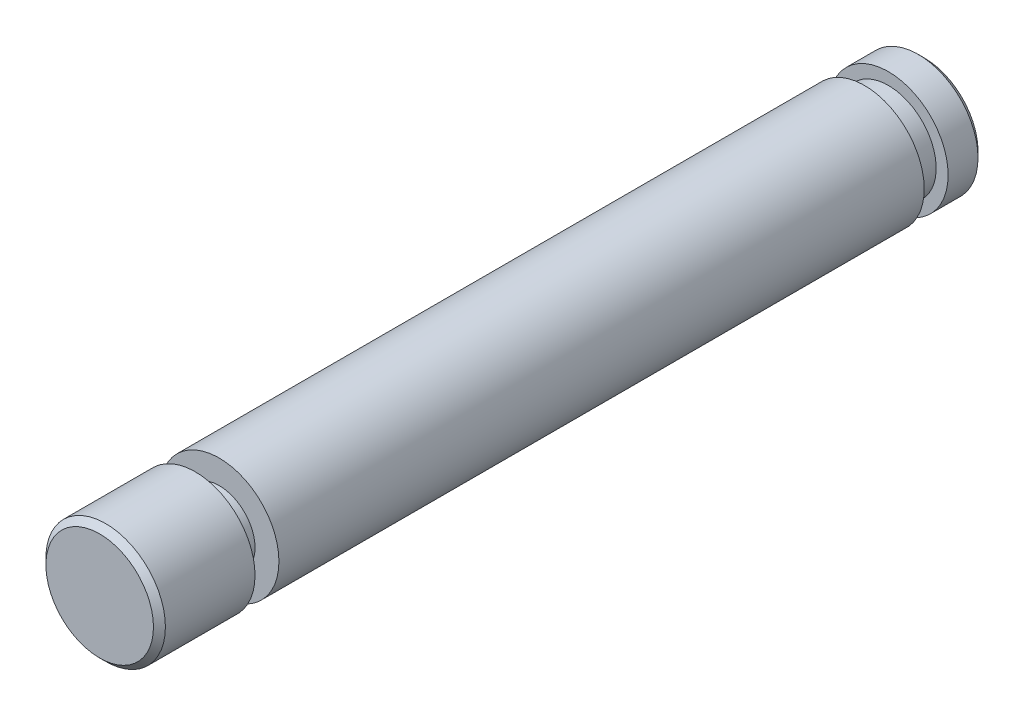
from build123d import *

# Parameters (mm, degrees)
SKETCH1_R           = 5
BOSS_EXTRUDE1_DEPTH = 34.5
CUT_EXTRUDE1_START  = -10
SKETCH2_R           = 5
SKETCH2_R_2         = 3
CUT_EXTRUDE1_DEPTH  = 2
CUT_EXTRUDE2_START  = -5
SKETCH4_R           = 5
SKETCH4_R_2         = 4
CUT_EXTRUDE2_DEPTH  = 2
CHAMFER1_SIZE       = 0.5
CUT_EXTRUDE4_START  = -3.2
CUT_EXTRUDE4_DEPTH  = 2.8


with BuildPart() as part:
    # Sketch1 → Boss-Extrude1 (new body, symmetric)
    with BuildSketch(Plane.XY):
        Circle(SKETCH1_R)
    extrude(amount=BOSS_EXTRUDE1_DEPTH, both=True)

    # Sketch2 → Cut-Extrude1 (cut)
    with BuildSketch(Plane.XY.offset(34.5).offset(CUT_EXTRUDE1_START)):
        Circle(SKETCH2_R)
        Circle(SKETCH2_R_2, mode=Mode.SUBTRACT)
    extrude(amount=CUT_EXTRUDE1_DEPTH, mode=Mode.SUBTRACT)

    # Sketch4 → Cut-Extrude2 (cut)
    with BuildSketch(Plane(origin=(0, 0, -34.5), x_dir=(-1, 0, 0), z_dir=(0, 0, -1)).offset(CUT_EXTRUDE2_START)):
        Circle(SKETCH4_R)
        Circle(SKETCH4_R_2, mode=Mode.SUBTRACT)
    extrude(amount=CUT_EXTRUDE2_DEPTH, mode=Mode.SUBTRACT)

    # Chamfer1
    chamfer1_edges = [part.edges().sort_by_distance(p)[0] for p in [
        (-5, 0, -34.5),
        (-5, 0, 34.5),
    ]]
    chamfer(chamfer1_edges, length=CHAMFER1_SIZE)

    # Sketch7 → Cut-Extrude4 (cut, through all)
    with BuildSketch(Plane(origin=(0, 0, 0), x_dir=(0, 0, -1), z_dir=(1, 0, 0)).offset(CUT_EXTRUDE4_START)):
        with BuildLine():
            Line((8, 1.5), (34.5, 1.5))
            Line((34.5, 1.5), (34.5, -1.5))
            Line((34.5, -1.5), (8, -1.5))
            ThreePointArc((8, -1.5), (6.5, 0), (8, 1.5))
        make_face()
    extrude(amount=-CUT_EXTRUDE4_DEPTH, mode=Mode.SUBTRACT)


solid = part.part
